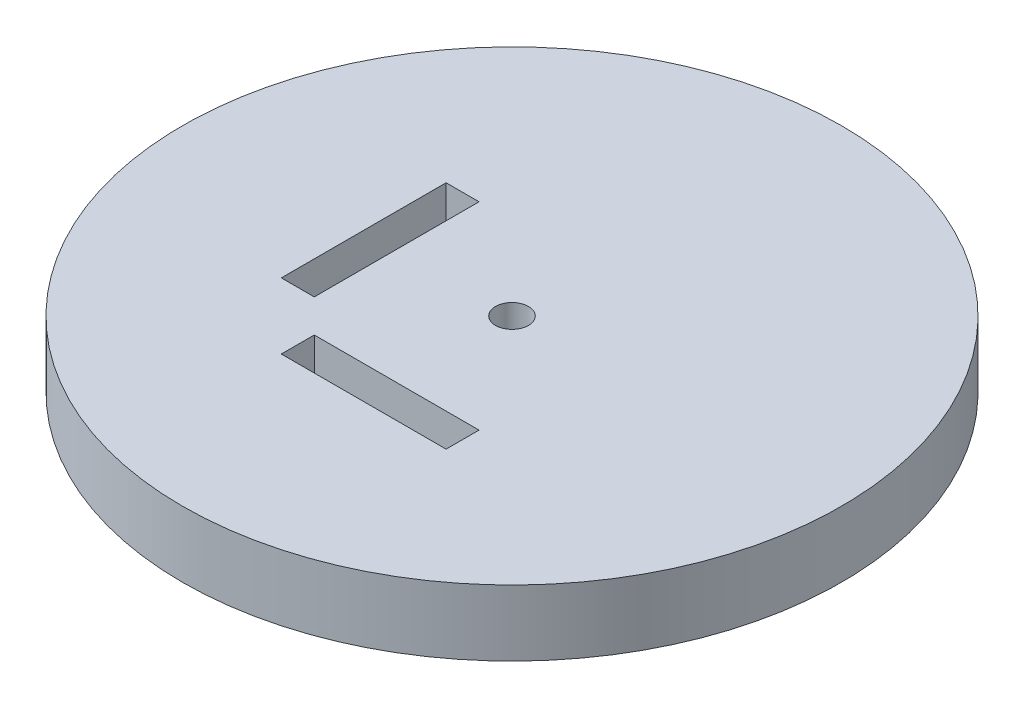
from build123d import *

# Parameters (mm, degrees)
SKETCH1_R           = 50
BOSS_EXTRUDE1_DEPTH = 10
SKETCH2_R           = 2.5
SKETCH2_W           = 5
SKETCH2_H           = 25
SKETCH2_W_2         = 25
SKETCH2_H_2         = 5
CUT_EXTRUDE1_DEPTH  = 72.414284285


with BuildPart() as part:
    # Sketch1 → Boss-Extrude1 (new body)
    with BuildSketch(Plane(origin=(0, 0, 0), x_dir=(1, 0, 0), z_dir=(0, 1, 0))):
        Circle(SKETCH1_R)
    extrude(amount=BOSS_EXTRUDE1_DEPTH)

    # Sketch2 → Cut-Extrude1 (cut, through all)
    with BuildSketch(Plane(origin=(0, 10, 0), x_dir=(1, 0, 0), z_dir=(0, 1, 0))):
        Circle(SKETCH2_R)
        with Locations((-20, 0)):
            Rectangle(SKETCH2_W, SKETCH2_H)
        with Locations((0, -20)):
            Rectangle(SKETCH2_W_2, SKETCH2_H_2)
    extrude(amount=-CUT_EXTRUDE1_DEPTH, mode=Mode.SUBTRACT)


solid = part.part
